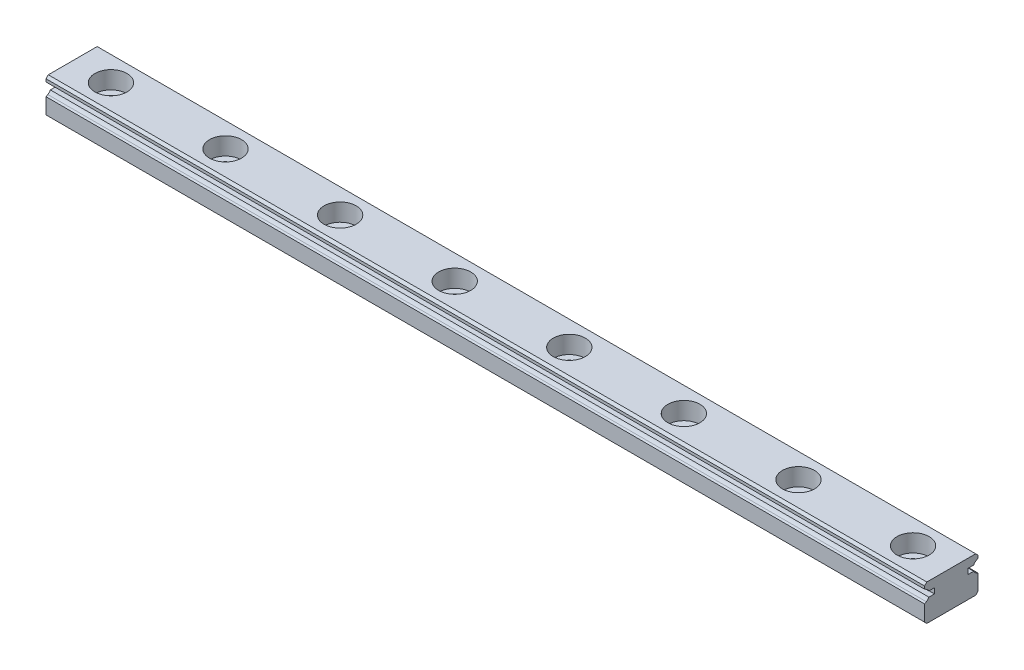
from build123d import *

# Parameters (mm, degrees)
SKETCH1_W                                    = 7
SKETCH1_H                                    = 4.7
BOSS_EXTRUDE1_DEPTH                          = 115
CUT_EXTRUDE1_DEPTH                           = 116
CBORE_FOR_SOCKET_HEAD_CAP_SCREW1_D           = 2.4
CBORE_FOR_SOCKET_HEAD_CAP_SCREW1_CBORE_D     = 4.2
CBORE_FOR_SOCKET_HEAD_CAP_SCREW1_CBORE_DEPTH = 2.3
LPATTERN1_COUNT                              = 8
LPATTERN1_PITCH                              = 15
CHAMFER1_SIZE                                = 0.3
CHAMFER2_SIZE                                = 0.3


with BuildPart() as part:
    # Sketch1 → Boss-Extrude1 (new body)
    with BuildSketch(Plane(origin=(-5, 0, 0), x_dir=(0, 0, -1), z_dir=(1, 0, 0))):
        with Locations((0, 2.35)):
            Rectangle(SKETCH1_W, SKETCH1_H)
    extrude(amount=BOSS_EXTRUDE1_DEPTH)

    # Sketch2 → Cut-Extrude1 (cut, through all)
    with BuildSketch(Plane(origin=(-5, 0, 0), x_dir=(0, 0, -1), z_dir=(1, 0, 0))):
        with BuildLine():
            Line((3.5, 4.034892917), (3.27, 3.902102355))
            ThreePointArc((3.27, 3.902102355), (3.075750359, 3.750022453), (2.931347317, 3.55))
            Line((2.931347317, 3.55), (2.2, 3.55))
            Line((2.2, 3.55), (2.2, 2.85))
            Line((2.2, 2.85), (2.931347317, 2.85))
            ThreePointArc((2.931347317, 2.85), (3.075750359, 2.649977547), (3.27, 2.497897645))
            Line((3.27, 2.497897645), (3.5, 2.365107083))
            Line((3.5, 2.365107083), (3.5, 4.034892917))
        make_face()
        with BuildLine():
            Line((-3.5, 4.034892917), (-3.5, 2.365107083))
            Line((-3.5, 2.365107083), (-3.27, 2.497897645))
            ThreePointArc((-3.27, 2.497897645), (-3.075750359, 2.649977547), (-2.931347317, 2.85))
            Line((-2.931347317, 2.85), (-2.2, 2.85))
            Line((-2.2, 2.85), (-2.2, 3.55))
            Line((-2.2, 3.55), (-2.931347317, 3.55))
            ThreePointArc((-2.931347317, 3.55), (-3.075750359, 3.750022453), (-3.27, 3.902102355))
            Line((-3.27, 3.902102355), (-3.5, 4.034892917))
        make_face()
    extrude(amount=CUT_EXTRUDE1_DEPTH, mode=Mode.SUBTRACT)

    # CBORE for Socket Head Cap Screw1 (through all)
    with Locations(Plane(origin=(0, 4.7, 0), x_dir=(1, 0, 0), z_dir=(0, 1, 0))):
        with Locations((0, 0)):
            cbore_for_socket_head_cap_screw1 = CounterBoreHole(CBORE_FOR_SOCKET_HEAD_CAP_SCREW1_D / 2, CBORE_FOR_SOCKET_HEAD_CAP_SCREW1_CBORE_D / 2, CBORE_FOR_SOCKET_HEAD_CAP_SCREW1_CBORE_DEPTH)

    # LPattern1: CBORE for Socket Head Cap Screw1 ×8
    with Locations(*[(i * LPATTERN1_PITCH, 0, 0) for i in range(1, LPATTERN1_COUNT)]):
        add(cbore_for_socket_head_cap_screw1, mode=Mode.SUBTRACT)

    # Chamfer1
    chamfer1_edges = [part.edges().sort_by_distance(p)[0] for p in [
        (52.5, 4.7, 3.5),
        (52.5, 4.7, -3.5),
    ]]
    chamfer(chamfer1_edges, length=CHAMFER1_SIZE)

    # Chamfer2
    chamfer2_edges = [part.edges().sort_by_distance(p)[0] for p in [
        (52.5, 0, -3.5),
        (52.5, 0, 3.5),
    ]]
    chamfer(chamfer2_edges, length=CHAMFER2_SIZE)


solid = part.part
